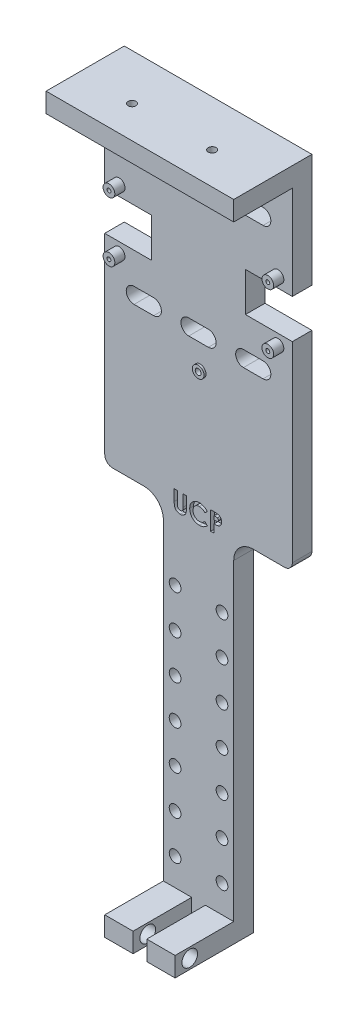
from build123d import *

# Parameters (mm, degrees)
ESBO_O1_W                         = 18
ESBO_O1_H                         = 180
RESSALTO_EXTRUS_O1_DEPTH          = 2.5
ESBO_O2_W                         = 7.25
ESBO_O2_H                         = 5
RESSALTO_EXTRUS_O2_DEPTH          = 15
ESBO_O5_W                         = 15
ESBO_O5_H                         = 90
RESSALTO_EXTRUS_O5_DEPTH          = 5
ESBO_O3_W                         = 48
ESBO_O3_H                         = 5
RESSALTO_EXTRUS_O3_DEPTH          = 15
FILETE1_R                         = 2
ESBO_O6_R                         = 0.5
ESBO_O6_R_2                       = 0.75
CORTE_EXTRUS_O1_DEPTH             = 95.345111161
CORTE_EXTRUS_O1_DEPTH_BACK        = 95.345111161
CORTE_EXTRUS_O2_REACH             = 184.434
ESBO_O7_R                         = 1
CORTE_EXTRUS_O2_DIRECTION_2_DEPTH = 183.434234726
CORTE_EXTRUS_O3_REACH             = 96.345
ESBO_O8_W                         = 12
ESBO_O8_H                         = 10
FILETE2_R                         = 5
CORTE_EXTRUS_O4_DEPTH             = 95.345111161
CORTE_EXTRUS_O4_DEPTH_BACK        = 95.345111161
CORTE_EXTRUS_O6_DEPTH             = 95.345111161
CORTE_EXTRUS_O6_DEPTH_BACK        = 1
ESBO_O12_R                        = 2
CORTE_EXTRUS_O7_DEPTH             = 98.443573542
CORTE_EXTRUS_O7_DEPTH_BACK        = 98.443573542
ESBO_O13_R                        = 1.5
CORTE_EXTRUS_O8_DEPTH             = 95.345111282
CORTE_EXTRUS_O8_DEPTH_BACK        = 95.345111282
ESBO_O14_R                        = 1.5
ESBO_O14_R_2                      = 0.5
RESSALTO_EXTRUS_O6_DEPTH          = 2.6
ESBO_O15_R                        = 1.5
ESBO_O15_R_2                      = 0.75
RESSALTO_EXTRUS_O7_DEPTH          = 0.5


with BuildPart() as part:
    # Esboço1 → Ressalto-extrusão1 (new, symmetric)
    with BuildSketch(Plane.XY):
        Rectangle(ESBO_O1_W, ESBO_O1_H)
    extrude(amount=RESSALTO_EXTRUS_O1_DEPTH, both=True)

    # Esboço2 → Ressalto-extrusão2 (add)
    with BuildSketch(Plane.XY.offset(2.5)):
        with Locations((-5.375, -87.5)):
            Rectangle(ESBO_O2_W, ESBO_O2_H)
        with Locations((5.375, -87.5)):
            Rectangle(ESBO_O2_W, ESBO_O2_H)
    extrude(amount=RESSALTO_EXTRUS_O2_DEPTH)

    # Esboço5 → Ressalto-extrusão5 (add)
    with BuildSketch(Plane.XY.offset(2.5)):
        with Locations((-16.5, 45)):
            Rectangle(ESBO_O5_W, ESBO_O5_H)
        with Locations((16.5, 45)):
            Rectangle(ESBO_O5_W, ESBO_O5_H)
    extrude(amount=-RESSALTO_EXTRUS_O5_DEPTH)

    # Esboço3 → Ressalto-extrusão3 (add)
    with BuildSketch(Plane.XY.offset(2.5)):
        with Locations((0, 87.5)):
            Rectangle(ESBO_O3_W, ESBO_O3_H)
    extrude(amount=RESSALTO_EXTRUS_O3_DEPTH)

    # Filete1
    filete1_edges = [part.edges().sort_by_distance(p)[0] for p in [
        (-24, 0, 0),
        (24, 0, 0),
    ]]
    fillet(filete1_edges, radius=FILETE1_R)

    # Esboço6 → Corte-extrusão1 (cut, two sides)
    with BuildSketch(Plane.XY.offset(2.5)) as corte_extrus_o1_sk:
        with Locations((-20.32, 63.62)):
            Circle(ESBO_O6_R)
        with Locations((20.32, 63.62)):
            Circle(ESBO_O6_R)
        with Locations((20.32, 48.38)):
            Circle(ESBO_O6_R)
        with Locations((-20.32, 48.38)):
            Circle(ESBO_O6_R)
        with Locations((0.4, 32.75)):
            Circle(ESBO_O6_R_2)
    extrude(amount=CORTE_EXTRUS_O1_DEPTH, mode=Mode.SUBTRACT)
    extrude(corte_extrus_o1_sk.sketch, amount=-CORTE_EXTRUS_O1_DEPTH_BACK, mode=Mode.SUBTRACT)

    # Esboço7 → Corte-extrusão2 (cut, up to next)
    with BuildSketch(Plane(origin=(0, 90, 0), x_dir=(1, 0, 0), z_dir=(0, 1, 0)), mode=Mode.PRIVATE) as corte_extrus_o2_sk1:
        with Locations(Location((-10.25, -9.27, 0), (0, 0, 90))):
            Circle(ESBO_O7_R)
    corte_extrus_o2_tool1 = extrude(corte_extrus_o2_sk1.sketch, amount=-CORTE_EXTRUS_O2_REACH, mode=Mode.PRIVATE) & part.part
    # Esboço7 → Corte-extrusão2 (cut, up to next)
    with BuildSketch(Plane(origin=(0, 90, 0), x_dir=(1, 0, 0), z_dir=(0, 1, 0)), mode=Mode.PRIVATE) as corte_extrus_o2_sk2:
        with Locations(Location((10.25, -9.27, 0), (0, 0, 90))):
            Circle(ESBO_O7_R)
    corte_extrus_o2_tool2 = extrude(corte_extrus_o2_sk2.sketch, amount=-CORTE_EXTRUS_O2_REACH, mode=Mode.PRIVATE) & part.part
    add(corte_extrus_o2_tool1.solids().sort_by_distance((-10.25, 90, 9.27))[0], mode=Mode.SUBTRACT)
    add(corte_extrus_o2_tool2.solids().sort_by_distance((10.25, 90, 9.27))[0], mode=Mode.SUBTRACT)

    # Esboço7 → Corte-extrusão2 direction 2 (cut)
    with BuildSketch(Plane(origin=(0, 90, 0), x_dir=(1, 0, 0), z_dir=(0, 1, 0))):
        with Locations(Location((-10.25, -9.27, 0), (0, 0, 90))):
            Circle(ESBO_O7_R)
        with Locations(Location((10.25, -9.27, 0), (0, 0, 90))):
            Circle(ESBO_O7_R)
    extrude(amount=CORTE_EXTRUS_O2_DIRECTION_2_DEPTH, mode=Mode.SUBTRACT)

    # Esboço8 → Corte-extrusão3 (cut, up to next)
    with BuildSketch(Plane.XY.offset(2.5), mode=Mode.PRIVATE) as corte_extrus_o3_sk1:
        with Locations((-18, 56)):
            Rectangle(ESBO_O8_W, ESBO_O8_H)
    corte_extrus_o3_tool1 = extrude(corte_extrus_o3_sk1.sketch, amount=-CORTE_EXTRUS_O3_REACH, mode=Mode.PRIVATE) & part.part
    # Esboço8 → Corte-extrusão3 (cut, up to next)
    with BuildSketch(Plane.XY.offset(2.5), mode=Mode.PRIVATE) as corte_extrus_o3_sk2:
        with Locations((18, 56)):
            Rectangle(ESBO_O8_W, ESBO_O8_H)
    corte_extrus_o3_tool2 = extrude(corte_extrus_o3_sk2.sketch, amount=-CORTE_EXTRUS_O3_REACH, mode=Mode.PRIVATE) & part.part
    add(corte_extrus_o3_tool1.solids().sort_by_distance((-18, 56, 2.5))[0], mode=Mode.SUBTRACT)
    add(corte_extrus_o3_tool2.solids().sort_by_distance((18, 56, 2.5))[0], mode=Mode.SUBTRACT)

    # Filete2
    filete2_edges = [part.edges().sort_by_distance(p)[0] for p in [
        (-9, 0, 0),
        (9, 0, 0),
    ]]
    fillet(filete2_edges, radius=FILETE2_R)

    # Esboço10 → Corte-extrusão4 (cut, two sides)
    with BuildSketch(Plane.XY.offset(2.5)) as corte_extrus_o4_sk:
        with BuildLine():
            Line((-16.5, 77), (-11.5, 77))
            ThreePointArc((-11.5, 77), (-9.5, 75), (-11.5, 73))
            Line((-11.5, 73), (-16.5, 73))
            ThreePointArc((-16.5, 73), (-18.5, 75), (-16.5, 77))
        make_face()
        with BuildLine():
            Line((-2.5, 73), (2.5, 73))
            ThreePointArc((2.5, 73), (4.5, 75), (2.5, 77))
            Line((2.5, 77), (-2.5, 77))
            ThreePointArc((-2.5, 77), (-4.5, 75), (-2.5, 73))
        make_face()
        with BuildLine():
            Line((11.5, 73), (16.5, 73))
            ThreePointArc((16.5, 73), (18.5, 75), (16.5, 77))
            Line((16.5, 77), (11.5, 77))
            ThreePointArc((11.5, 77), (9.5, 75), (11.5, 73))
        make_face()
        with BuildLine():
            Line((-16.5, 39), (-11.5, 39))
            ThreePointArc((-11.5, 39), (-9.5, 41), (-11.5, 43))
            Line((-11.5, 43), (-16.5, 43))
            ThreePointArc((-16.5, 43), (-18.5, 41), (-16.5, 39))
        make_face()
        with BuildLine():
            Line((-2.5, 43), (2.5, 43))
            ThreePointArc((2.5, 43), (4.5, 41), (2.5, 39))
            Line((2.5, 39), (-2.5, 39))
            ThreePointArc((-2.5, 39), (-4.5, 41), (-2.5, 43))
        make_face()
        with BuildLine():
            Line((11.5, 43), (16.5, 43))
            ThreePointArc((16.5, 43), (18.5, 41), (16.5, 39))
            Line((16.5, 39), (11.5, 39))
            ThreePointArc((11.5, 39), (9.5, 41), (11.5, 43))
        make_face()
    extrude(amount=CORTE_EXTRUS_O4_DEPTH, mode=Mode.SUBTRACT)
    extrude(corte_extrus_o4_sk.sketch, amount=-CORTE_EXTRUS_O4_DEPTH_BACK, mode=Mode.SUBTRACT)

    # Esboço11 → Corte-extrusão6 (cut, two sides)
    with BuildSketch(Plane.XY.offset(2.5)) as corte_extrus_o6_sk:
        with BuildLine():
            Line((-6.227884615, 3.298033906), (-5.373076923, 3.298033906))
            Line((-5.373076923, 3.298033906), (-5.373076923, 0.199356021))
            add(Edge.make_bspline(
                [(-5.373076923, 0.199356021), (-5.373030443, 0.167230273), (-5.372940667, 0.105179722), (-5.36844643, 0.016157497), (-5.364333893, -0.065672567), (-5.356913709, -0.140220884), (-5.345951554, -0.207519342), (-5.335336611, -0.268000244), (-5.320970335, -0.320580746), (-5.299380119, -0.380431124), (-5.266116684, -0.447676293), (-5.211766077, -0.51776075), (-5.149050127, -0.581722989), (-5.073881447, -0.634962734), (-4.989398499, -0.678028889), (-4.896065479, -0.709936144), (-4.794013953, -0.727672341), (-4.72345092, -0.730380096), (-4.687131911, -0.731773786)],
                knots=[0, 0, 0, 0, 1.155499968, 2.231836252, 3.205919964, 4.102923608, 4.924856345, 5.658536265, 6.31071849, 6.882491295, 7.94666036, 8.992281882, 10.060072772, 11.158554251, 12.289267114, 13.461410017, 14.693379945, 16, 16, 16, 16], degree=3))
            add(Edge.make_bspline(
                [(-4.687131911, -0.731773786), (-4.648547446, -0.730647864), (-4.573314271, -0.728452505), (-4.465103325, -0.706902685), (-4.36484527, -0.672587992), (-4.274662912, -0.623612179), (-4.194645994, -0.564906084), (-4.126913351, -0.497962739), (-4.073458997, -0.422648625), (-4.038619438, -0.35316562), (-4.019058741, -0.289212564), (-4.004397025, -0.232072936), (-3.993648365, -0.164653831), (-3.983896827, -0.088008143), (-3.978036904, -0.001341971), (-3.971682773, 0.094647704), (-3.969353925, 0.20061767), (-3.968956989, 0.274406546), (-3.96875, 0.312885168)],
                knots=[0, 0, 0, 0, 1.261321664, 2.459363699, 3.594844139, 4.716940403, 5.803436589, 6.833651888, 7.818396249, 8.814403945, 9.360733334, 10.004355033, 10.743453831, 11.592799886, 12.532235708, 13.585170094, 14.740740724, 16, 16, 16, 16], degree=3))
            Line((-3.96875, 0.312885168), (-3.96875, 3.298033906))
            Line((-3.96875, 3.298033906), (-3.113942308, 3.298033906))
            Line((-3.113942308, 3.298033906), (-3.113942308, 0.456943161))
            add(Edge.make_bspline(
                [(-3.113942308, 0.456943161), (-3.114061013, 0.399382798), (-3.114289273, 0.288699834), (-3.117794647, 0.129640626), (-3.125256954, -0.015634446), (-3.131524432, -0.147167832), (-3.143654147, -0.264782333), (-3.156290465, -0.368980199), (-3.172396539, -0.459392174), (-3.196361409, -0.56231522), (-3.23771768, -0.680827338), (-3.30438941, -0.817288905), (-3.389024857, -0.950893045), (-3.489059725, -1.08017002), (-3.602008242, -1.200264164), (-3.725366097, -1.305691277), (-3.85717344, -1.394871247), (-3.998807564, -1.465623514), (-4.15014793, -1.520804949), (-4.31269194, -1.557884094), (-4.48632875, -1.58293523), (-4.606262977, -1.5853417), (-4.668051382, -1.586581479)],
                knots=[0, 0, 0, 0, 1.170808336, 2.251350247, 3.235597562, 4.129743112, 4.929140599, 5.639994148, 6.264258765, 6.79612947, 7.788252245, 8.809469599, 9.879094798, 10.999557536, 12.129761673, 13.226370002, 14.293821979, 15.358369427, 16.438775801, 17.562147481, 18.744053101, 20, 20, 20, 20], degree=3))
            add(Edge.make_bspline(
                [(-4.668051382, -1.586581479), (-4.709104828, -1.585889988), (-4.790102435, -1.58452569), (-4.909223624, -1.572496148), (-5.024377654, -1.554769126), (-5.135348151, -1.528907227), (-5.242520271, -1.495498483), (-5.345865543, -1.454374647), (-5.44499991, -1.405765101), (-5.539368631, -1.350116948), (-5.628855575, -1.28994305), (-5.710642023, -1.223237752), (-5.787542439, -1.154934161), (-5.857335201, -1.082157773), (-5.920544514, -1.005672615), (-5.977040201, -0.925305348), (-6.026738325, -0.841063109), (-6.070889018, -0.751427438), (-6.108677701, -0.651842477), (-6.140534981, -0.538765948), (-6.168366251, -0.410425489), (-6.189048808, -0.266531955), (-6.207799736, -0.107559605), (-6.219668039, 0.06690571), (-6.225876883, 0.256868995), (-6.227198461, 0.388566602), (-6.227884615, 0.456943161)],
                knots=[0, 0, 0, 0, 1.001158378, 1.975264943, 2.917723546, 3.841610987, 4.75185031, 5.653588123, 6.552117133, 7.442167995, 8.324307438, 9.179605724, 10.014504199, 10.831958861, 11.636465792, 12.43274043, 13.225645099, 14.020104002, 14.867201867, 15.819789774, 16.883317127, 18.068162734, 19.364263498, 20.787406516, 22.332041935, 24, 24, 24, 24], degree=3))
            Line((-6.227884615, 0.456943161), (-6.227884615, 3.298033906))
        make_face()
        with BuildLine():
            Line((2.259134615, 2.471847007), (1.632339243, 1.872718401))
            add(Edge.make_bspline(
                [(1.632339243, 1.872718401), (1.579169353, 1.927696156), (1.4753119, 2.035084936), (1.30795846, 2.177258217), (1.133916976, 2.29574041), (0.956573076, 2.395525359), (0.77273686, 2.471019784), (0.584533974, 2.526033843), (0.390762687, 2.559573836), (0.259625733, 2.563411404), (0.193667368, 2.565341598)],
                knots=[0, 0, 0, 0, 1.115251505, 2.178435587, 3.19620269, 4.182487026, 5.141301733, 6.088180966, 7.038406374, 8, 8, 8, 8], degree=3))
            add(Edge.make_bspline(
                [(0.193667368, 2.565341598), (0.138584117, 2.563816678), (0.02988339, 2.560807414), (-0.129717761, 2.538746548), (-0.282384511, 2.501231085), (-0.428639462, 2.449527827), (-0.568052252, 2.382626556), (-0.700915177, 2.300579051), (-0.82690067, 2.204126318), (-0.944344535, 2.093767408), (-1.051778055, 1.973192005), (-1.146702411, 1.844538338), (-1.226216786, 1.708101145), (-1.29147294, 1.565262162), (-1.342304961, 1.415360259), (-1.378605411, 1.258496355), (-1.399600621, 1.09448364), (-1.402734297, 0.982989017), (-1.404326923, 0.92632417)],
                knots=[0, 0, 0, 0, 1.035432265, 2.043311493, 3.022114605, 3.98653278, 4.95457646, 5.923598177, 6.917315552, 7.932509744, 8.948865224, 9.949768934, 10.933144597, 11.912367597, 12.897413939, 13.903909035, 14.934704909, 16, 16, 16, 16], degree=3))
            add(Edge.make_bspline(
                [(-1.404326923, 0.92632417), (-1.403867946, 0.886552816), (-1.402963294, 0.80816266), (-1.393060272, 0.692201862), (-1.377114072, 0.579692474), (-1.354035969, 0.470804916), (-1.325176575, 0.365444828), (-1.291317934, 0.262703271), (-1.248842768, 0.163999904), (-1.201694692, 0.06818835), (-1.146862024, -0.022117052), (-1.087742291, -0.108230747), (-1.023636594, -0.189730615), (-0.954129715, -0.266283482), (-0.878243433, -0.336692998), (-0.797939125, -0.403076461), (-0.71186217, -0.463772068), (-0.621800605, -0.520303041), (-0.52697641, -0.569411979), (-0.429962387, -0.613895189), (-0.329287608, -0.650022169), (-0.226177847, -0.679143811), (-0.121001584, -0.703907419), (-0.012730096, -0.719155133), (0.097698038, -0.730702048), (0.172328921, -0.731415002), (0.209885817, -0.731773786)],
                knots=[0, 0, 0, 0, 1.103660481, 2.175337485, 3.227646561, 4.255952547, 5.262355991, 6.258840057, 7.255597736, 8.242457506, 9.22035537, 10.185017736, 11.140346927, 12.096287581, 13.051739095, 14.01125915, 14.986044842, 15.97314143, 16.960198552, 17.947847494, 18.933482797, 19.925264591, 20.920966487, 21.929612487, 22.958107872, 24, 24, 24, 24], degree=3))
            add(Edge.make_bspline(
                [(0.209885817, -0.731773786), (0.273588768, -0.729931159), (0.398748501, -0.726310875), (0.582438406, -0.69800077), (0.757476586, -0.651432248), (0.897331253, -0.596437529), (1.006903692, -0.542129531), (1.090319569, -0.491897307), (1.176578087, -0.435707049), (1.264246567, -0.371438077), (1.354311104, -0.299861642), (1.445181852, -0.219410089), (1.539185118, -0.132732571), (1.600765725, -0.070869124), (1.632339243, -0.039150589)],
                knots=[0, 0, 0, 0, 1.404581149, 2.759636711, 4.088442092, 5.392261763, 6.066678138, 6.783632037, 7.538459478, 8.336747902, 9.180226004, 10.074962426, 11.012997595, 12, 12, 12, 12], degree=3))
            Line((1.632339243, -0.039150589), (2.240054087, -0.677394279))
            add(Edge.make_bspline(
                [(2.240054087, -0.677394279), (2.197335004, -0.718638212), (2.113956491, -0.799137549), (1.988182318, -0.913439096), (1.862566438, -1.016151742), (1.740143467, -1.111003506), (1.61890799, -1.195231126), (1.498872863, -1.268918722), (1.381396938, -1.333929958), (1.264040787, -1.389168453), (1.146074162, -1.436071673), (1.024700368, -1.476452266), (0.899548353, -1.510612795), (0.769853747, -1.538175856), (0.636826261, -1.56027771), (0.499220935, -1.575196333), (0.357910255, -1.585225627), (0.262057032, -1.586126842), (0.213701923, -1.586581479)],
                knots=[0, 0, 0, 0, 1.244526981, 2.429050516, 3.560637417, 4.644440555, 5.67424972, 6.652764056, 7.595344123, 8.486817594, 9.369275933, 10.254498637, 11.166417451, 12.086725134, 13.032340136, 13.991389299, 14.986715468, 16, 16, 16, 16], degree=3))
            add(Edge.make_bspline(
                [(0.213701923, -1.586581479), (0.124879578, -1.58431722), (-0.048921061, -1.579886695), (-0.303621366, -1.547059505), (-0.545579819, -1.4920253), (-0.775385059, -1.414191754), (-0.992964014, -1.314763047), (-1.19826102, -1.19286812), (-1.390945185, -1.04883083), (-1.569459999, -0.884339434), (-1.730935143, -0.702672495), (-1.873660472, -0.507612042), (-1.991722869, -0.298199423), (-2.089752621, -0.077528332), (-2.166410598, 0.155408239), (-2.220364818, 0.400862257), (-2.253637992, 0.65859672), (-2.257278124, 0.8346353), (-2.259134615, 0.924416117)],
                knots=[0, 0, 0, 0, 1.078019885, 2.10938526, 3.111377082, 4.085535484, 5.04941344, 6.010039228, 6.978205633, 7.964457913, 8.951525778, 9.924444315, 10.892603023, 11.863865945, 12.85144698, 13.863884204, 14.910567087, 16, 16, 16, 16], degree=3))
            add(Edge.make_bspline(
                [(-2.259134615, 0.924416117), (-2.258350152, 0.982970401), (-2.256795538, 1.099010679), (-2.240456397, 1.26994741), (-2.217678685, 1.436580147), (-2.181543916, 1.59717869), (-2.137987016, 1.753906597), (-2.083818288, 1.905060419), (-2.019124247, 2.051074588), (-1.945990134, 2.19219354), (-1.863254244, 2.327492794), (-1.770829173, 2.455809917), (-1.671094301, 2.578135493), (-1.561653162, 2.692846646), (-1.444096081, 2.800950563), (-1.317892298, 2.901861408), (-1.183800869, 2.997026357), (-1.041458856, 3.083991335), (-0.893631587, 3.16265578), (-0.742183551, 3.232041181), (-0.587486839, 3.290031397), (-0.430195523, 3.338132143), (-0.269645049, 3.374035948), (-0.106981385, 3.401213971), (0.059179541, 3.416406659), (0.170742208, 3.418893799), (0.227058293, 3.420149291)],
                knots=[0, 0, 0, 0, 1.071919942, 2.124283339, 3.142214191, 4.149696895, 5.136002878, 6.119640489, 7.086990633, 8.058538607, 9.028339693, 9.988281803, 10.952401235, 11.916291999, 12.888973767, 13.874849856, 14.873389453, 15.898127285, 16.927174885, 17.938320013, 18.946391617, 19.950418109, 20.947802303, 21.956882652, 22.968648068, 24, 24, 24, 24], degree=3))
            add(Edge.make_bspline(
                [(0.227058293, 3.420149291), (0.275101689, 3.419429611), (0.370688962, 3.417997736), (0.513034452, 3.406061495), (0.65424153, 3.38731575), (0.79380463, 3.359032412), (0.932722052, 3.325456516), (1.069168263, 3.281493511), (1.205295777, 3.232488458), (1.338969636, 3.173912922), (1.470376429, 3.109972435), (1.596437745, 3.037429629), (1.719270143, 2.96074871), (1.836151728, 2.875391363), (1.949271947, 2.784453658), (2.058039282, 2.687511321), (2.161499237, 2.582948037), (2.22642496, 2.509067904), (2.259134615, 2.471847007)],
                knots=[0, 0, 0, 0, 0.996412454, 1.982464992, 2.961075852, 3.949442424, 4.934965278, 5.923860011, 6.921385422, 7.934793307, 8.949617135, 9.951082467, 10.950285876, 11.951772932, 12.951063433, 13.960125323, 14.972308753, 16, 16, 16, 16], degree=3))
        make_face()
        with BuildLine():
            Line((3.113942308, 3.298033906), (4.06796875, 3.298033906))
            add(Edge.make_bspline(
                [(4.06796875, 3.298033906), (4.1303036, 3.297754882), (4.250560592, 3.297216586), (4.423981069, 3.290689032), (4.583969949, 3.278991258), (4.730490477, 3.26453466), (4.863482406, 3.244267071), (4.983112282, 3.221031867), (5.089404932, 3.192724627), (5.183558962, 3.159124325), (5.268059163, 3.119510882), (5.348023607, 3.077319737), (5.421645089, 3.026966093), (5.492639507, 2.973876853), (5.556947988, 2.912980422), (5.61858248, 2.848329545), (5.674932594, 2.777360222), (5.726259436, 2.700931518), (5.772820791, 2.620455508), (5.813499905, 2.535788324), (5.846496524, 2.446795991), (5.874176585, 2.354054186), (5.896409479, 2.257566953), (5.911208401, 2.156740886), (5.921260574, 2.05227999), (5.922147539, 1.981183839), (5.922596154, 1.945224411)],
                knots=[0, 0, 0, 0, 1.698747864, 3.27724071, 4.728299578, 6.070144658, 7.288476769, 8.393259625, 9.389771311, 10.283485332, 11.113357557, 11.931608583, 12.74405601, 13.541433047, 14.344816069, 15.154114104, 15.974336324, 16.810834471, 17.661136416, 18.50621059, 19.367396281, 20.244825668, 21.142564693, 22.063065223, 23.020325768, 24, 24, 24, 24], degree=3))
            add(Edge.make_bspline(
                [(5.922596154, 1.945224411), (5.921947065, 1.905443351), (5.920671525, 1.827268681), (5.908167123, 1.712674205), (5.886805655, 1.603418748), (5.858887333, 1.498580938), (5.819957219, 1.39988559), (5.775481392, 1.304977802), (5.720762017, 1.216518498), (5.658236384, 1.133401159), (5.589951258, 1.05495), (5.514285556, 0.983430152), (5.432681497, 0.918354065), (5.345611458, 0.859039737), (5.252748552, 0.805606819), (5.154159784, 0.757554967), (5.049171934, 0.716421029), (4.976061555, 0.694908313), (4.938994892, 0.684001454)],
                knots=[0, 0, 0, 0, 1.102006807, 2.165578795, 3.188629044, 4.184801286, 5.166646146, 6.124351954, 7.085497154, 8.042432466, 9.003981491, 9.963833307, 10.922997304, 11.89326795, 12.880200226, 13.889073926, 14.929769137, 16, 16, 16, 16], degree=3))
            add(Edge.make_bspline(
                [(4.938994892, 0.684001454), (4.914580656, 0.677927153), (4.861691558, 0.664768259), (4.774174628, 0.65140868), (4.673320555, 0.639125368), (4.558803212, 0.628569349), (4.430556577, 0.621393715), (4.288704826, 0.615789865), (4.133183674, 0.611715287), (4.025040415, 0.611570703), (3.96875, 0.611495444)],
                knots=[0, 0, 0, 0, 0.618981996, 1.340914327, 2.176866532, 3.120127938, 4.170906482, 5.338178032, 6.614476169, 8, 8, 8, 8], degree=3))
            Line((3.96875, 0.611495444), (3.96875, -1.464466094))
            Line((3.96875, -1.464466094), (3.113942308, -1.464466094))
            Line((3.113942308, -1.464466094), (3.113942308, 3.298033906))
        make_face()
        with BuildLine():
            Line((3.96875, 1.466303137), (4.271176382, 1.466303137))
            add(Edge.make_bspline(
                [(4.271176382, 1.466303137), (4.326207637, 1.466652078), (4.427465964, 1.467294134), (4.56574908, 1.476578642), (4.676876052, 1.490757962), (4.764668424, 1.511094386), (4.833988817, 1.541957602), (4.893773316, 1.577660532), (4.945052007, 1.622805905), (4.989451806, 1.67439222), (5.024948107, 1.73366748), (5.049562943, 1.799666504), (5.065552257, 1.871002582), (5.067029018, 1.920647771), (5.067788462, 1.946178437)],
                knots=[0, 0, 0, 0, 1.8619151, 3.425951444, 4.686033666, 5.651700536, 6.461346321, 7.243864085, 7.999046032, 8.762387399, 9.539336099, 10.322741239, 11.137448474, 12, 12, 12, 12], degree=3))
            add(Edge.make_bspline(
                [(5.067788462, 1.946178437), (5.06703683, 1.968484248), (5.065578484, 2.011762883), (5.05486508, 2.074224688), (5.037790995, 2.132451976), (5.013051303, 2.18583664), (4.981068738, 2.23428797), (4.94207552, 2.27778688), (4.896572008, 2.317264936), (4.861440636, 2.338161274), (4.843592248, 2.348777596)],
                knots=[0, 0, 0, 0, 1.102301479, 2.1387299, 3.123554645, 4.094223062, 5.036071848, 5.982632524, 6.975082478, 8, 8, 8, 8], degree=3))
            add(Edge.make_bspline(
                [(4.843592248, 2.348777596), (4.828473632, 2.356423513), (4.796464425, 2.372611487), (4.741949642, 2.39143119), (4.679040415, 2.407307683), (4.607312036, 2.420485019), (4.52705065, 2.430712), (4.438270576, 2.438533082), (4.340841167, 2.441678244), (4.273084843, 2.442695992), (4.237785457, 2.443226214)],
                knots=[0, 0, 0, 0, 0.656809284, 1.390599849, 2.23162475, 3.173112763, 4.218524733, 5.370385145, 6.63003504, 8, 8, 8, 8], degree=3))
            Line((4.237785457, 2.443226214), (3.96875, 2.443226214))
            Line((3.96875, 2.443226214), (3.96875, 1.466303137))
        make_face(mode=Mode.SUBTRACT)
    extrude(amount=CORTE_EXTRUS_O6_DEPTH, mode=Mode.SUBTRACT)
    extrude(corte_extrus_o6_sk.sketch, amount=-CORTE_EXTRUS_O6_DEPTH_BACK, mode=Mode.SUBTRACT)

    # Esboço12 → Corte-extrusão7 (cut, two sides)
    with BuildSketch(Plane(origin=(9, 0, 0), x_dir=(0, 0, -1), z_dir=(1, 0, 0))) as corte_extrus_o7_sk:
        with Locations((-13.75, -87.5)):
            Circle(ESBO_O12_R)
    extrude(amount=CORTE_EXTRUS_O7_DEPTH, mode=Mode.SUBTRACT)
    extrude(corte_extrus_o7_sk.sketch, amount=-CORTE_EXTRUS_O7_DEPTH_BACK, mode=Mode.SUBTRACT)

    # Esboço13 → Corte-extrusão8 (cut, two sides)
    with BuildSketch(Plane.XY.offset(2.5)) as corte_extrus_o8_sk:
        with Locations((-6, -78)):
            Circle(ESBO_O13_R)
        with Locations((6, -78)):
            Circle(ESBO_O13_R)
        with Locations((6, -68)):
            Circle(ESBO_O13_R)
        with Locations((6, -58)):
            Circle(ESBO_O13_R)
        with Locations((6, -48)):
            Circle(ESBO_O13_R)
        with Locations((6, -38)):
            Circle(ESBO_O13_R)
        with Locations((6, -28)):
            Circle(ESBO_O13_R)
        with Locations((6, -18)):
            Circle(ESBO_O13_R)
        with Locations((-6, -68)):
            Circle(ESBO_O13_R)
        with Locations((-6, -58)):
            Circle(ESBO_O13_R)
        with Locations((-6, -48)):
            Circle(ESBO_O13_R)
        with Locations((-6, -38)):
            Circle(ESBO_O13_R)
        with Locations((-6, -28)):
            Circle(ESBO_O13_R)
        with Locations((-6, -18)):
            Circle(ESBO_O13_R)
    extrude(amount=CORTE_EXTRUS_O8_DEPTH, mode=Mode.SUBTRACT)
    extrude(corte_extrus_o8_sk.sketch, amount=-CORTE_EXTRUS_O8_DEPTH_BACK, mode=Mode.SUBTRACT)

    # Esboço14 → Ressalto-extrusão6 (add)
    with BuildSketch(Plane.XY.offset(2.5)):
        with Locations(Location((20.32, 48.38, 0), (0, 0, 180))):
            Circle(ESBO_O14_R)
        with Locations((20.32, 48.38)):
            Circle(ESBO_O14_R_2, mode=Mode.SUBTRACT)
        with Locations(Location((20.32, 63.62, 0), (0, 0, 180))):
            Circle(ESBO_O14_R)
        with Locations((20.32, 63.62)):
            Circle(ESBO_O14_R_2, mode=Mode.SUBTRACT)
        with Locations(Location((-20.32, 48.38, 0), (0, 0, 180))):
            Circle(ESBO_O14_R)
        with Locations((-20.32, 48.38)):
            Circle(ESBO_O14_R_2, mode=Mode.SUBTRACT)
        with Locations(Location((-20.32, 63.62, 0), (0, 0, 180))):
            Circle(ESBO_O14_R)
        with Locations((-20.32, 63.62)):
            Circle(ESBO_O14_R_2, mode=Mode.SUBTRACT)
    extrude(amount=RESSALTO_EXTRUS_O6_DEPTH)

    # Esboço15 → Ressalto-extrusão7 (add)
    with BuildSketch(Plane.XY.offset(2.5)):
        with Locations(Location((0.4, 32.75, 0), (0, 0, 180))):
            Circle(ESBO_O15_R)
        with Locations((0.4, 32.75)):
            Circle(ESBO_O15_R_2, mode=Mode.SUBTRACT)
    extrude(amount=RESSALTO_EXTRUS_O7_DEPTH)


solid = part.part
